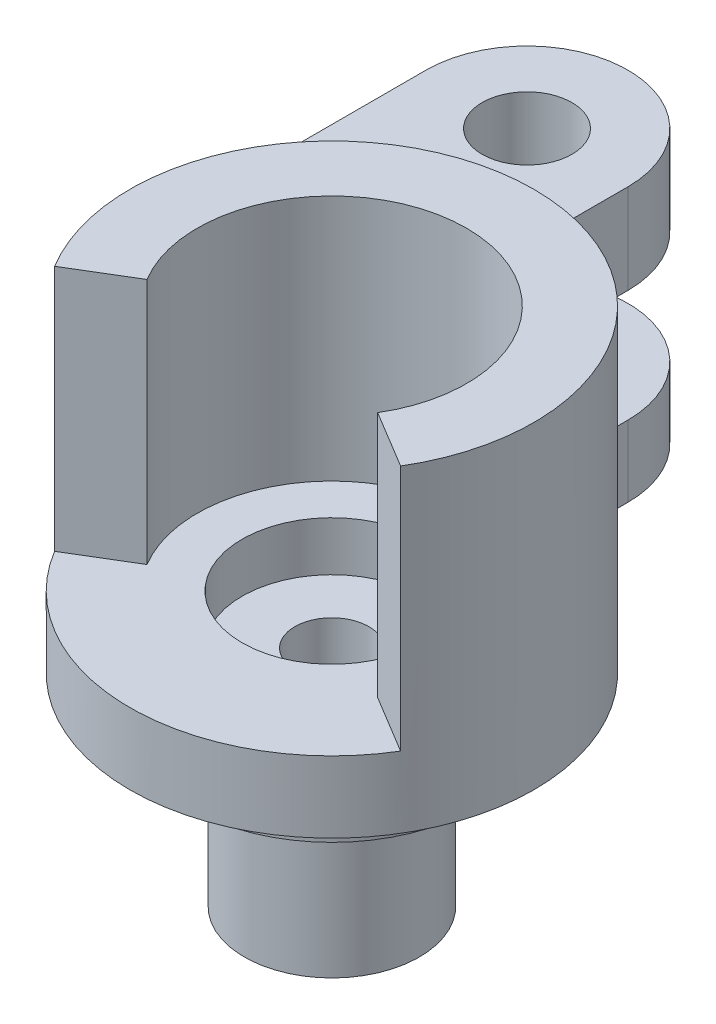
from build123d import *

# Parameters (mm, degrees)
SKETCH1_R           = 9
BOSS_EXTRUDE1_DEPTH = 3.175
BOSS_EXTRUDE2_DEPTH = 11
SKETCH3_R           = 6.399999954
BOSS_EXTRUDE3_DEPTH = 2
SKETCH4_R           = 3.9000049
BOSS_EXTRUDE4_DEPTH = 6.999999906
BOSS_EXTRUDE5_DEPTH = 3.175
BOSS_EXTRUDE7_DEPTH = 4
SKETCH8_R           = 2
CUT_EXTRUDE1_DEPTH  = 4
SKETCH9_R           = 1.650000048
CUT_EXTRUDE2_DEPTH  = 12.175
SKETCH10_R          = 4
CUT_EXTRUDE3_DEPTH  = 2.2
SKETCH11_R          = 1.7145
CUT_EXTRUDE4_DEPTH  = 1.5


with BuildPart() as part:
    # Sketch1 → Boss-Extrude1 (new body)
    with BuildSketch(Plane(origin=(0, 0, 0), x_dir=(1, 0, 0), z_dir=(0, 1, 0))):
        Circle(SKETCH1_R)
    extrude(amount=BOSS_EXTRUDE1_DEPTH)

    # Sketch2 → Boss-Extrude2 (add)
    with BuildSketch(Plane(origin=(0, 3.175, 0), x_dir=(1, 0, 0), z_dir=(0, 1, 0))):
        with BuildLine():
            Line((-7.707704384, -4.646643211), (-5.138469589, -3.097762141))
            ThreePointArc((-5.138469589, -3.097762141), (0, 6), (5.138469589, -3.097762141))
            Line((5.138469589, -3.097762141), (7.707704384, -4.646643211))
            ThreePointArc((7.707704384, -4.646643211), (0, 9), (-7.707704384, -4.646643211))
        make_face()
    extrude(amount=BOSS_EXTRUDE2_DEPTH)

    # Sketch3 → Boss-Extrude3 (add)
    with BuildSketch(Plane.XZ):
        Circle(SKETCH3_R)
    extrude(amount=BOSS_EXTRUDE3_DEPTH)

    # Sketch4 → Boss-Extrude4 (add)
    with BuildSketch(Plane.XZ.offset(2)):
        Circle(SKETCH4_R)
    extrude(amount=BOSS_EXTRUDE4_DEPTH)

    # Sketch6 → Boss-Extrude5 (add)
    with BuildSketch(Plane(origin=(0, 0, 0), x_dir=(1, 0, 0), z_dir=(0, 1, 0))):
        with BuildLine():
            Line((-9, 0), (-9, 13.194197425))
            ThreePointArc((-9, 13.194197425), (-4.5, 17.694197425), (0, 13.194197425))
            Line((0, 13.194197425), (0, 9))
            ThreePointArc((0, 9), (-6.363961031, 6.363961031), (-9, 0))
        make_face()
    extrude(amount=BOSS_EXTRUDE5_DEPTH)

    # Sketch7 → Boss-Extrude7 (add)
    with BuildSketch(Plane(origin=(0, 8.174999906, 0), x_dir=(1, 0, 0), z_dir=(0, 1, 0))):
        with BuildLine():
            Line((0, 9), (0, 13.194197425))
            ThreePointArc((0, 13.194197425), (-4.5, 17.694197425), (-9, 13.194197425))
            Line((-9, 13.194197425), (-9, 0))
            ThreePointArc((-9, 0), (-6.363961031, 6.363961031), (0, 9))
        make_face()
    extrude(amount=BOSS_EXTRUDE7_DEPTH)

    # Sketch8 → Cut-Extrude1 (cut)
    with BuildSketch(Plane(origin=(0, 12.174999906, 0), x_dir=(1, 0, 0), z_dir=(0, 1, 0))):
        with Locations((-4.5, 13.194197425)):
            Circle(SKETCH8_R)
    extrude(amount=-CUT_EXTRUDE1_DEPTH, mode=Mode.SUBTRACT)

    # Sketch9 → Cut-Extrude2 (cut)
    with BuildSketch(Plane(origin=(0, 3.175, 0), x_dir=(1, 0, 0), z_dir=(0, 1, 0))):
        Circle(SKETCH9_R)
    extrude(amount=-CUT_EXTRUDE2_DEPTH, mode=Mode.SUBTRACT)

    # Sketch10 → Cut-Extrude3 (cut)
    with BuildSketch(Plane(origin=(0, 3.175, 0), x_dir=(1, 0, 0), z_dir=(0, 1, 0))):
        Circle(SKETCH10_R)
    extrude(amount=-CUT_EXTRUDE3_DEPTH, mode=Mode.SUBTRACT)

    # Sketch11 → Cut-Extrude4 (cut)
    with BuildSketch(Plane(origin=(0, 3.175, 0), x_dir=(1, 0, 0), z_dir=(0, 1, 0))):
        with Locations((-4.5, 13.194197425)):
            Circle(SKETCH11_R)
    extrude(amount=-CUT_EXTRUDE4_DEPTH, mode=Mode.SUBTRACT)


solid = part.part
